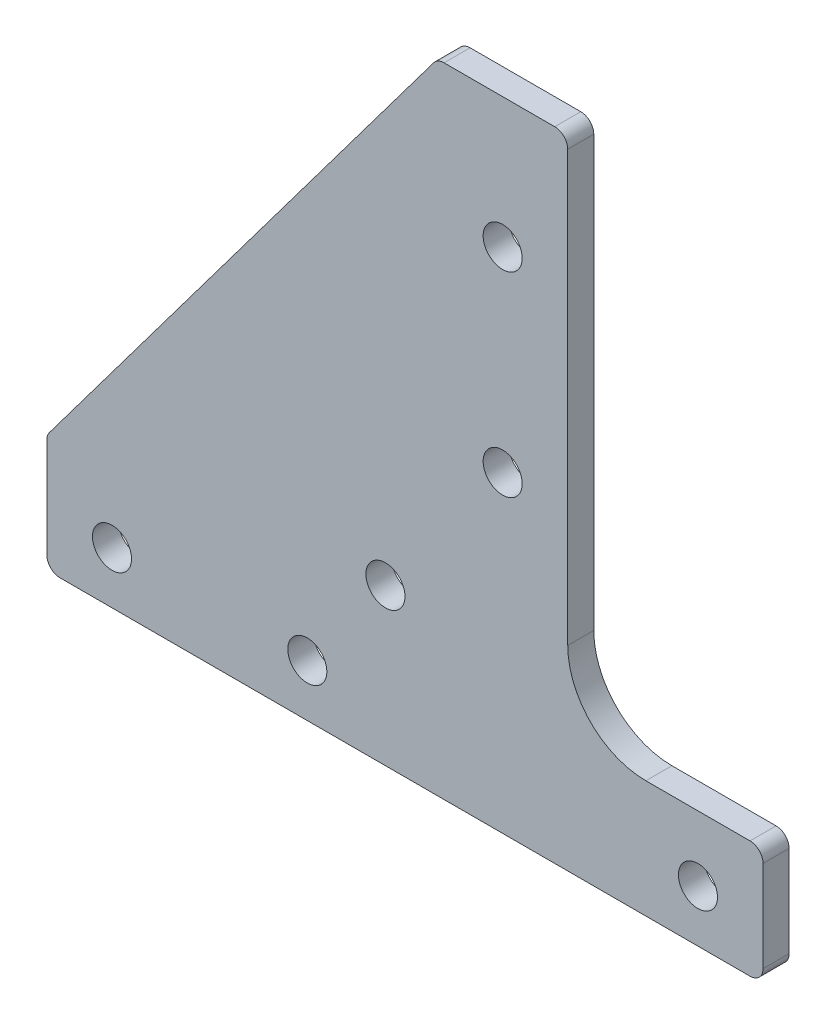
from build123d import *

# Parameters (mm, degrees)
SKETCH_1_R          = 1.5
EXTRUDE_1_DEPTH     = 2
CUT_EXTRUDE_1_DEPTH = 10
FILLET_1_R          = 1


with BuildPart() as part:
    # 草图1 → 凸台-拉伸1 (new body)
    with BuildSketch(Plane.XY):
        Polygon((-5, 45), (-35, 5), (-35, -4), (20, -4), (20, 5), (5, 45), align=None)
        with Locations((-30, 0)):
            Circle(SKETCH_1_R, mode=Mode.SUBTRACT)
        with Locations((-15, 0)):
            Circle(SKETCH_1_R, mode=Mode.SUBTRACT)
        with Locations((-9, 8)):
            Circle(SKETCH_1_R, mode=Mode.SUBTRACT)
        with Locations((15, 0)):
            Circle(SKETCH_1_R, mode=Mode.SUBTRACT)
        with Locations((0, 20)):
            Circle(SKETCH_1_R, mode=Mode.SUBTRACT)
        with Locations((0, 35)):
            Circle(SKETCH_1_R, mode=Mode.SUBTRACT)
    extrude(amount=EXTRUDE_1_DEPTH)

    # 草图2 → 切除-拉伸1 (cut)
    with BuildSketch(Plane.XY.offset(2)):
        with BuildLine():
            Line((5, 45), (5, 11))
            ThreePointArc((5, 11), (6.757359313, 6.757359313), (11, 5))
            Line((11, 5), (20, 5))
            Line((20, 5), (5, 45))
        make_face()
    extrude(amount=-CUT_EXTRUDE_1_DEPTH, mode=Mode.SUBTRACT)

    # 圆角1
    fillet_1_edges = [part.edges().sort_by_distance(p)[0] for p in [
        (20, -4, 1),
        (-35, -4, 1),
        (-35, 5, 1),
        (-5, 45, 1),
        (5, 45, 1),
        (20, 5, 1),
    ]]
    fillet(fillet_1_edges, radius=FILLET_1_R)


solid = part.part
